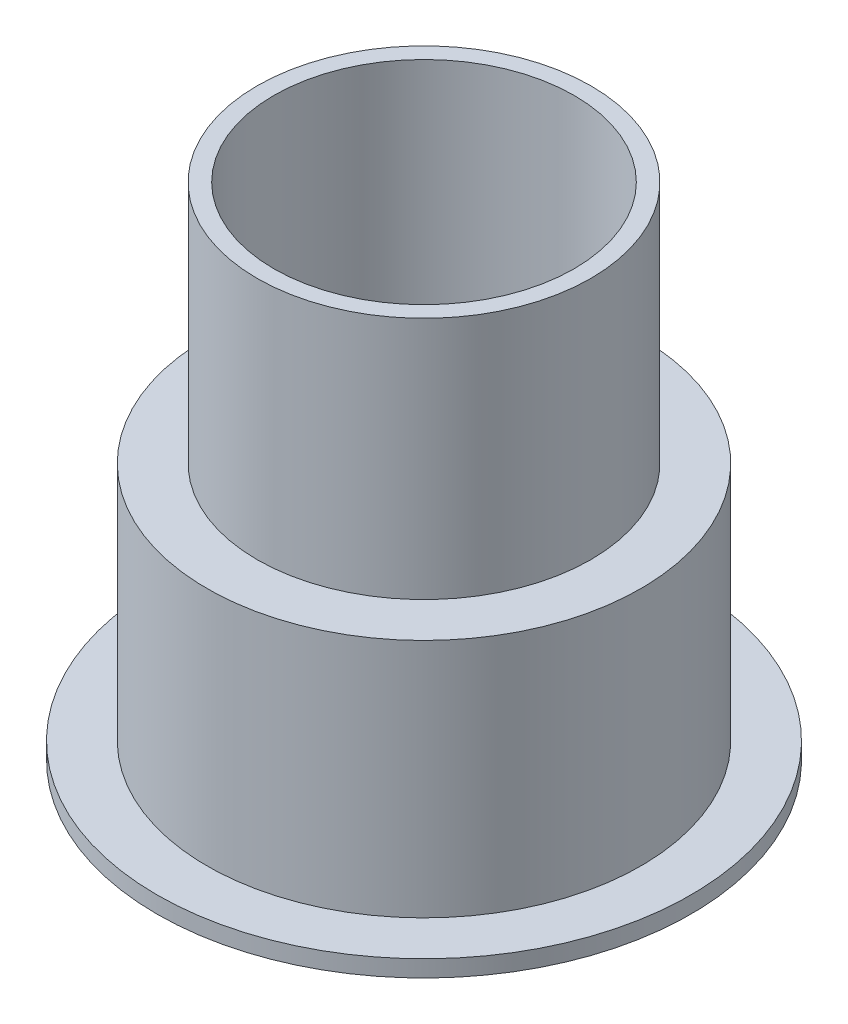
from build123d import *


with BuildPart() as part:
    # Sketch1 → Revolve1 (revolve)
    with BuildSketch(Plane.XY):
        Polygon((6, -0.854835863), (6, 6.145164137), (0, 6.145164137), (0, 6.845164137), (4.5, 6.845164137), (4.5, 14.145164137), (5, 14.145164137), (5, 6.845164137), (6.5, 6.845164137), (6.5, -0.354835863), (8, -0.354835863), (8, -0.854835863), align=None)
    revolve(axis=Axis((0, 0, 0), (0, 1, 0)))


solid = part.part
